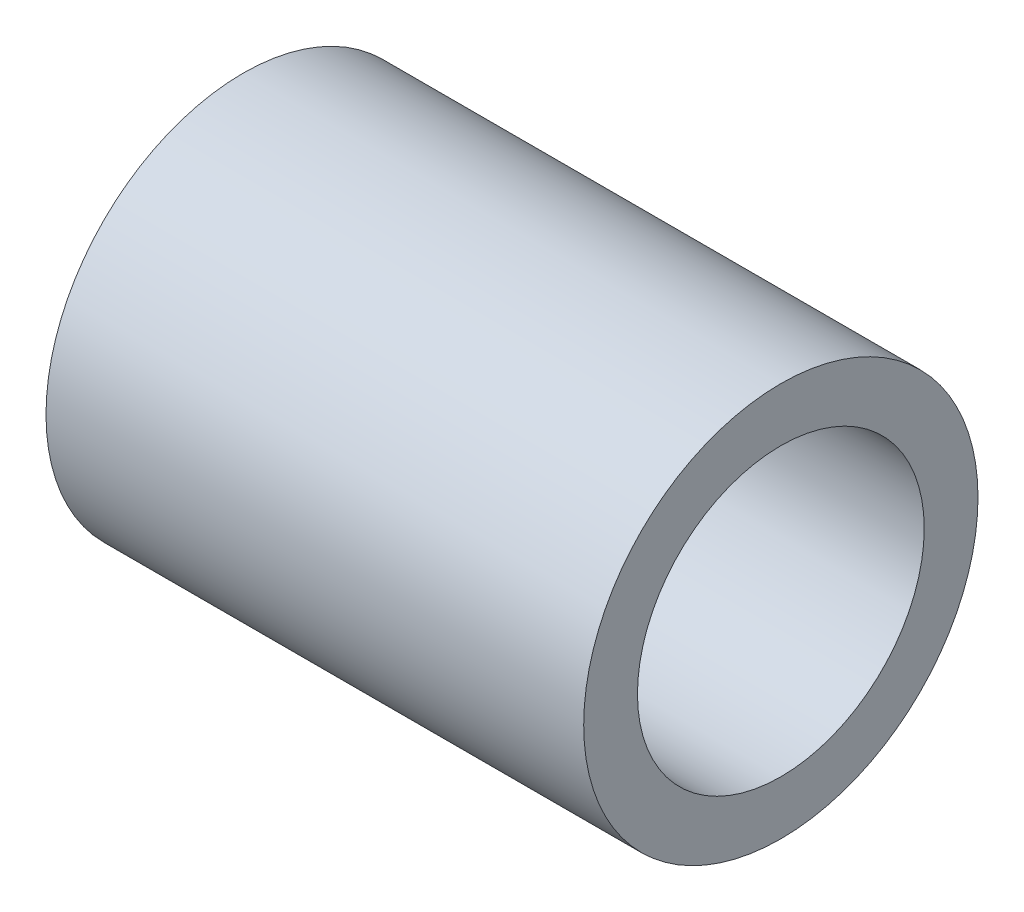
from build123d import *

# Parameters (mm, degrees)
SKETCH_1_R      = 11
SKETCH_1_R_2    = 8
EXTRUDE_1_DEPTH = 30


with BuildPart() as part:
    # 草图1 → 凸台-拉伸1 (new body)
    with BuildSketch(Plane(origin=(0, 0, 0), x_dir=(0, 0, -1), z_dir=(1, 0, 0))):
        Circle(SKETCH_1_R)
        Circle(SKETCH_1_R_2, mode=Mode.SUBTRACT)
    extrude(amount=-EXTRUDE_1_DEPTH)


solid = part.part
